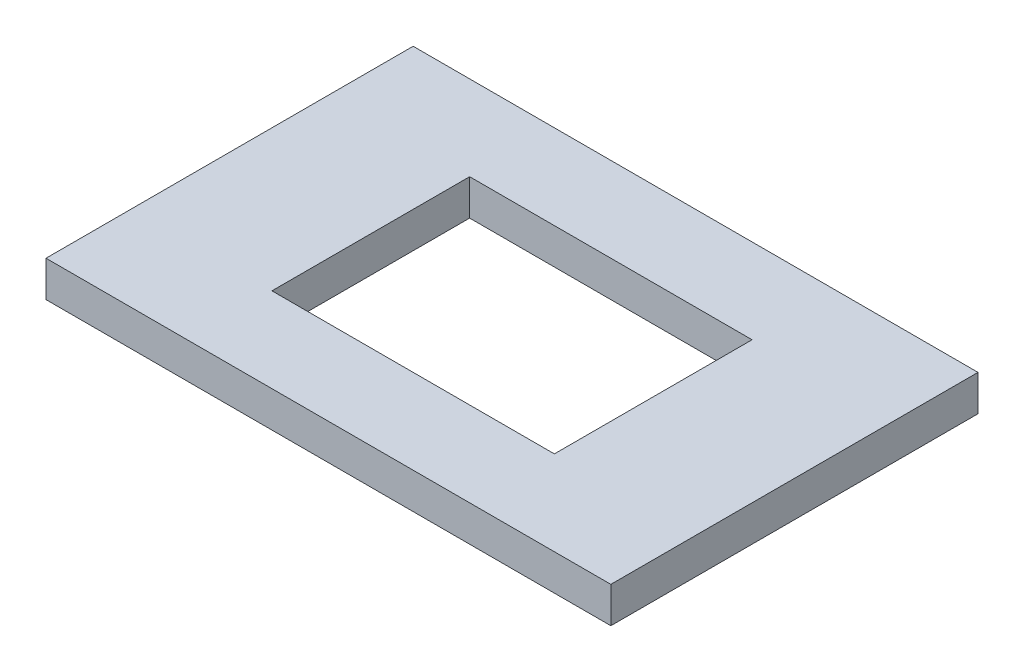
from build123d import *

# Parameters (mm, degrees)
SKETCH1_W           = 100
SKETCH1_H           = 65
BOSS_EXTRUDE1_DEPTH = 6.35
SKETCH2_W           = 50
SKETCH2_H           = 35
CUT_EXTRUDE1_DEPTH  = 6.35


with BuildPart() as part:
    # Sketch1 → Boss-Extrude1 (new body)
    with BuildSketch(Plane(origin=(0, 0, 0), x_dir=(1, 0, 0), z_dir=(0, 1, 0))):
        with Locations((-8.080017258, -4.110267289)):
            Rectangle(SKETCH1_W, SKETCH1_H)
    extrude(amount=BOSS_EXTRUDE1_DEPTH)

    # Sketch2 → Cut-Extrude1 (cut)
    with BuildSketch(Plane(origin=(0, 6.35, 0), x_dir=(1, 0, 0), z_dir=(0, 1, 0))):
        with Locations((-8.080017258, -4.110267289)):
            Rectangle(SKETCH2_W, SKETCH2_H)
    extrude(amount=-CUT_EXTRUDE1_DEPTH, mode=Mode.SUBTRACT)


solid = part.part
